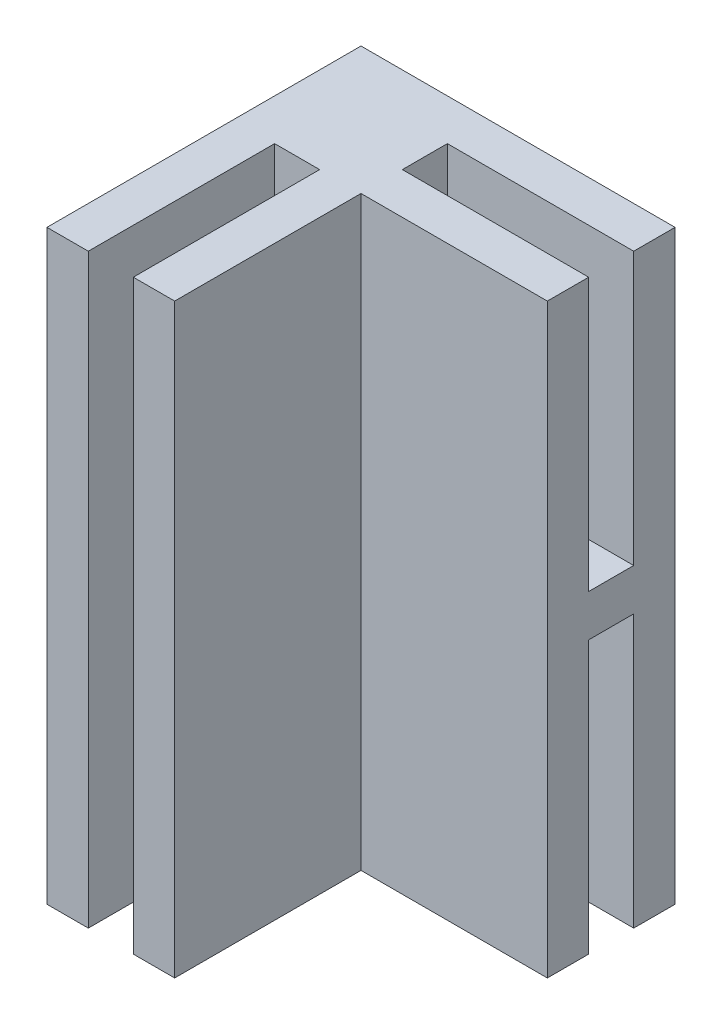
from build123d import *

# Parameters (mm, degrees)
ESQUISSE1_W             = 30
ESQUISSE1_H             = 30
BOSS_EXTRU_1_DEPTH      = 56
ESQUISSE2_W             = 17.8
ESQUISSE2_H             = 4.3
ENL_V_MAT_EXTRU_1_DEPTH = 26
ESQUISSE3_W             = 4.3
ESQUISSE3_H             = 17.8
ESQUISSE3_W_2           = 17.8
ENL_V_MAT_EXTRU_2_DEPTH = 57
ESQUISSE4_W             = 17.8
ESQUISSE4_H             = 4.3
ENL_V_MAT_EXTRU_3_DEPTH = 26


with BuildPart() as part:
    # Esquisse1 → Boss.-Extru.1 (new body)
    with BuildSketch(Plane(origin=(0, 0, 0), x_dir=(1, 0, 0), z_dir=(0, 1, 0))):
        with Locations((3.620689655, -5.615763547)):
            Rectangle(ESQUISSE1_W, ESQUISSE1_H)
    extrude(amount=BOSS_EXTRU_1_DEPTH)

    # Esquisse2 → Enlèv. mat.-Extru.1 (cut)
    with BuildSketch(Plane.XZ):
        with Locations((9.720689655, -3.284236453)):
            Rectangle(ESQUISSE2_W, ESQUISSE2_H)
    extrude(amount=-ENL_V_MAT_EXTRU_1_DEPTH, mode=Mode.SUBTRACT)

    # Esquisse3 → Enlèv. mat.-Extru.2 (cut, through all)
    with BuildSketch(Plane.XZ):
        with Locations((-5.279310345, 11.715763547)):
            Rectangle(ESQUISSE3_W, ESQUISSE3_H)
        with Locations((9.720689655, 11.715763547)):
            Rectangle(ESQUISSE3_W_2, ESQUISSE3_H)
    extrude(amount=-ENL_V_MAT_EXTRU_2_DEPTH, mode=Mode.SUBTRACT)

    # Esquisse4 → Enlèv. mat.-Extru.3 (cut)
    with BuildSketch(Plane(origin=(0, 56, 0), x_dir=(1, 0, 0), z_dir=(0, 1, 0))):
        with Locations((9.720689655, 3.284236453)):
            Rectangle(ESQUISSE4_W, ESQUISSE4_H)
    extrude(amount=-ENL_V_MAT_EXTRU_3_DEPTH, mode=Mode.SUBTRACT)


solid = part.part
